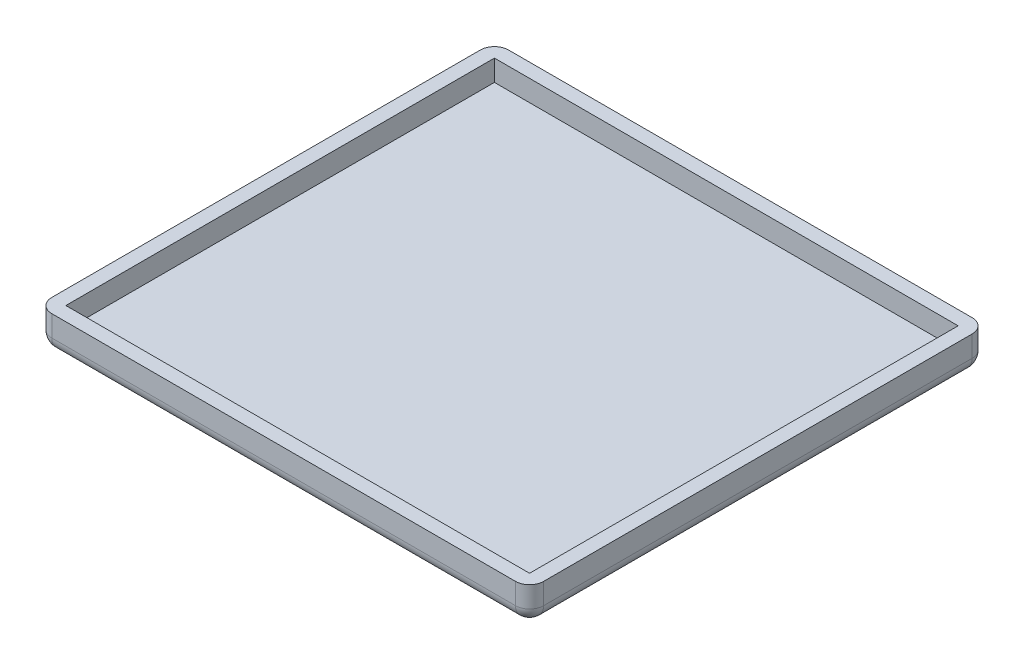
from build123d import *

# Parameters (mm, degrees)
SKETCH1_W           = 70
SKETCH1_H           = 65
SKETCH1_W_2         = 66
SKETCH1_H_2         = 61
BOSS_EXTRUDE1_DEPTH = 5
SKETCH2_W           = 66
SKETCH2_H           = 61
BOSS_EXTRUDE2_DEPTH = 2
FILLET2_R           = 2


with BuildPart() as part:
    # Sketch1 → Boss-Extrude1 (new body)
    with BuildSketch(Plane(origin=(0, 0, 0), x_dir=(1, 0, 0), z_dir=(0, 1, 0))):
        Rectangle(SKETCH1_W, SKETCH1_H)
        Rectangle(SKETCH1_W_2, SKETCH1_H_2, mode=Mode.SUBTRACT)
    extrude(amount=BOSS_EXTRUDE1_DEPTH)

    # Sketch2 → Boss-Extrude2 (add)
    with BuildSketch(Plane(origin=(0, 0, 0), x_dir=(1, 0, 0), z_dir=(0, 1, 0))):
        Rectangle(SKETCH2_W, SKETCH2_H)
    extrude(amount=BOSS_EXTRUDE2_DEPTH)

    # Fillet2
    fillet2_edges = [part.edges().sort_by_distance(p)[0] for p in [
        (0, 0, 32.5),
        (-35, 0, 0),
        (0, 0, -32.5),
        (35, 0, 0),
        (35, 2.5, 32.5),
        (-35, 2.5, 32.5),
        (-35, 2.5, -32.5),
        (35, 2.5, -32.5),
    ]]
    fillet(fillet2_edges, radius=FILLET2_R)


solid = part.part
